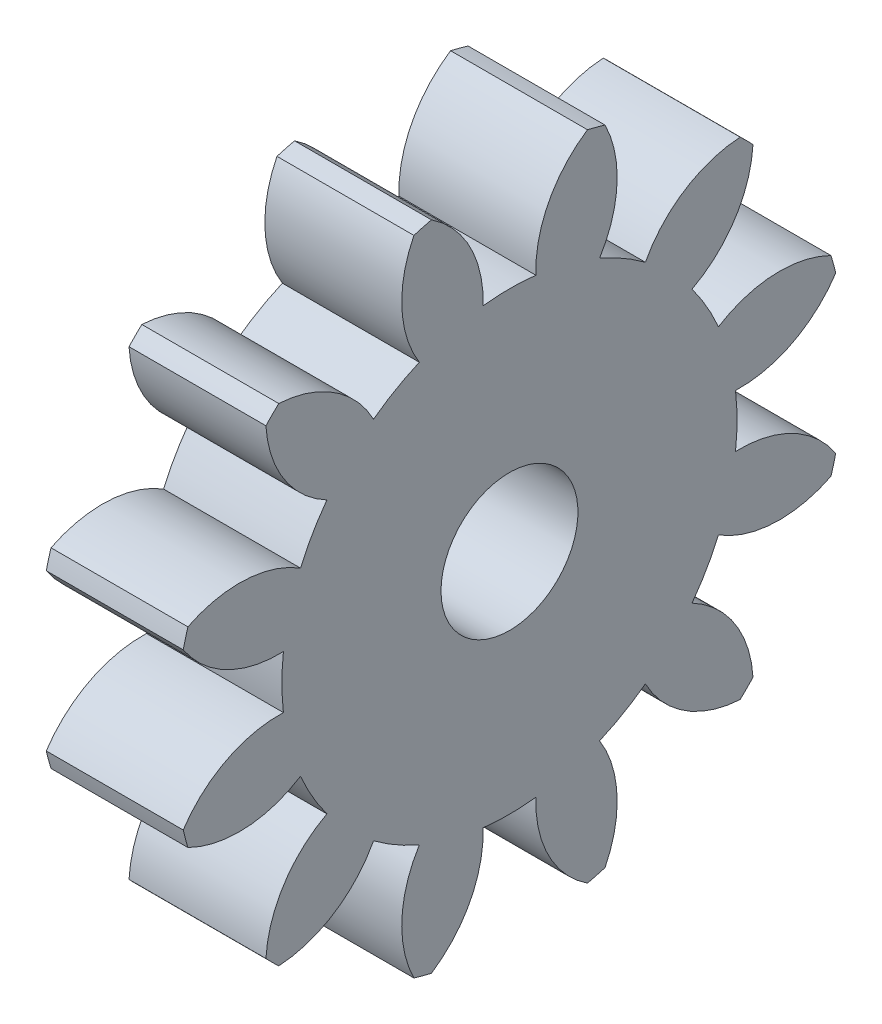
from build123d import *

# Parameters (mm, degrees)
BASPROSKE_W     = 5
BASPROSKE_H     = 12.25
TOOTHCUT_DEPTH  = 19.03122292
TEETHCUTS_COUNT = 12
TEETHCUTS_ANGLE = 330
BORSKE_R        = 2.5
BORE_DEPTH      = 50.0000508


with BuildPart() as part:
    # BasProSke → Base-Revolve (revolve)
    with BuildSketch(Plane(origin=(0, 0, 0), x_dir=(1, 0, 0), z_dir=(0, 1, 0)), mode=Mode.PRIVATE) as base_revolve_sk:
        with Locations((2.5, 6.125)):
            Rectangle(BASPROSKE_W, BASPROSKE_H)
    revolve(base_revolve_sk.sketch.rotate(Axis((-10, 0, 0), (1, 0, 0)), 180), axis=Axis((-10, 0, 0), (1, 0, 0)))

    # TooCutSke → ToothCut (cut, through all)
    with BuildSketch(Plane(origin=(0, 0, 0), x_dir=(0, 0, -1), z_dir=(1, 0, 0))):
        with BuildLine():
            ThreePointArc((0.965128363, 8.255274647), (0, 8.3115), (-0.965128363, 8.255274647))
            ThreePointArc((-0.965128363, 8.255274647), (-1.43628674, 10.346733197), (-2.878284339, 11.933185846))
            ThreePointArc((-2.878284339, 11.933185846), (0, 12.2754), (2.878284339, 11.933185846))
            ThreePointArc((2.878284339, 11.933185846), (1.43628674, 10.346733197), (0.965128363, 8.255274647))
        make_face()
    toothcut = extrude(amount=TOOTHCUT_DEPTH, mode=Mode.SUBTRACT)

    # TeethCuts: ToothCut ×12 about axis
    teethcuts_axis = Axis((-10, 0, 0), (1, 0, 0))
    for i in range(1, TEETHCUTS_COUNT):
        add(toothcut.rotate(teethcuts_axis, i * TEETHCUTS_ANGLE / (TEETHCUTS_COUNT - 1)), mode=Mode.SUBTRACT)

    # BorSke → Bore (cut, symmetric)
    with BuildSketch(Plane(origin=(0, 0, 0), x_dir=(0, 0, -1), z_dir=(1, 0, 0))):
        with Locations(Location((0, 0, 0), (0, 0, 180))):
            Circle(BORSKE_R)
    extrude(amount=BORE_DEPTH, both=True, mode=Mode.SUBTRACT)


solid = part.part
